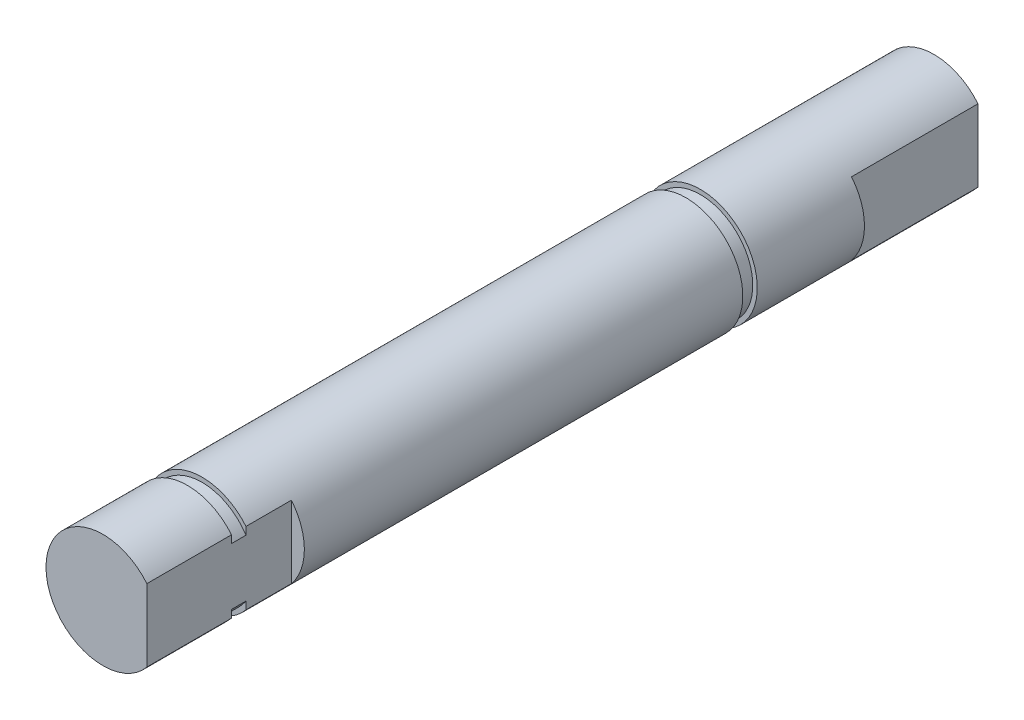
from build123d import *

# Parameters (mm, degrees)
SKETCH1_R           = 4.000000001
BOSS_EXTRUDE1_DEPTH = 58.42
CUT_EXTRUDE1_DEPTH  = 10.16
CUT_EXTRUDE5_DEPTH  = 8.89
CUT_EXTRUDE3_START  = -16.423386
SKETCH4_OUTSIDE_W   = 21.902
SKETCH4_OUTSIDE_H   = 21.902
SKETCH4_OUTSIDE_R   = 3.683
CUT_EXTRUDE3_DEPTH  = 1.016
CUT_EXTRUDE4_START  = -5.94995
SKETCH5_OUTSIDE_W   = 21.902
SKETCH5_OUTSIDE_H   = 21.902
SKETCH5_OUTSIDE_R   = 3.683
CUT_EXTRUDE4_DEPTH  = 1.016


with BuildPart() as part:
    # Sketch1 → Boss-Extrude1 (new body)
    with BuildSketch(Plane.XY):
        Circle(SKETCH1_R)
    extrude(amount=BOSS_EXTRUDE1_DEPTH)

    # Sketch2 → Cut-Extrude1 (cut)
    with BuildSketch(Plane.XY.offset(58.42)):
        with BuildLine():
            Line((3.090048545, 2.54), (3.090048545, -2.54))
            ThreePointArc((3.090048545, -2.54), (4.000000001, 0), (3.090048545, 2.54))
        make_face()
    extrude(amount=-CUT_EXTRUDE1_DEPTH, mode=Mode.SUBTRACT)

    # Sketch6 → Cut-Extrude5 (cut)
    with BuildSketch(Plane(origin=(0, 0, 0), x_dir=(-1, 0, 0), z_dir=(0, 0, -1))):
        with BuildLine():
            Line((-3.090048545, 2.54), (-3.090048545, -2.54))
            ThreePointArc((-3.090048545, -2.54), (-4.000000001, 0), (-3.090048545, 2.54))
        make_face()
    extrude(amount=-CUT_EXTRUDE5_DEPTH, mode=Mode.SUBTRACT)

    # Sketch4 outside → Cut-Extrude3 (cut)
    with BuildSketch(Plane(origin=(0, 0, 0), x_dir=(-1, 0, 0), z_dir=(0, 0, -1)).offset(CUT_EXTRUDE3_START)):
        Rectangle(SKETCH4_OUTSIDE_W, SKETCH4_OUTSIDE_H)
        Circle(SKETCH4_OUTSIDE_R, mode=Mode.SUBTRACT)
    extrude(amount=-CUT_EXTRUDE3_DEPTH, mode=Mode.SUBTRACT)

    # Sketch5 outside → Cut-Extrude4 (cut)
    with BuildSketch(Plane.XY.offset(58.42).offset(CUT_EXTRUDE4_START)):
        Rectangle(SKETCH5_OUTSIDE_W, SKETCH5_OUTSIDE_H)
        Circle(SKETCH5_OUTSIDE_R, mode=Mode.SUBTRACT)
    extrude(amount=-CUT_EXTRUDE4_DEPTH, mode=Mode.SUBTRACT)


solid = part.part
